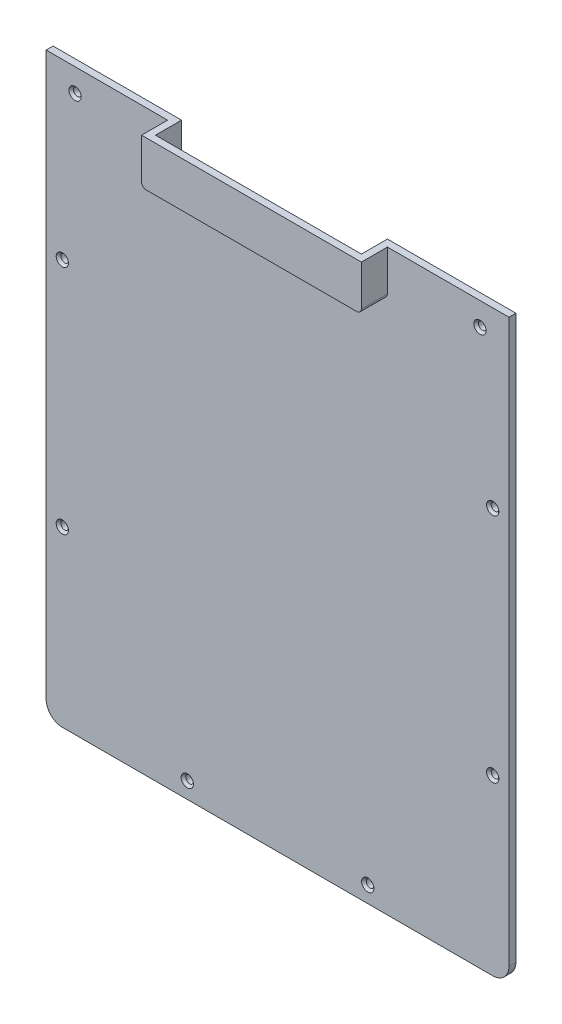
from build123d import *

# Parameters (mm, degrees)
SKETCH1_W           = 200
SKETCH1_H           = 250
BOSS_EXTRUDE1_DEPTH = 3
FILLET1_R           = 7
SKETCH2_W           = 89
SKETCH2_H           = 16.5
CUT_EXTRUDE2_DEPTH  = 3
EXTRUDE_THIN1_DEPTH = 8.25
SKETCH4_W           = 95
SKETCH4_H           = 19.5
BOSS_EXTRUDE2_DEPTH = 3
FILLET2_R           = 2
FILLET3_R           = 2
SKETCH5_R           = 1.65
CUT_EXTRUDE3_DEPTH  = 4
CHAMFER1_SIZE       = 1


with BuildPart() as part:
    # Sketch1 → Boss-Extrude1 (new body)
    with BuildSketch(Plane.XY):
        with Locations((100, 125)):
            Rectangle(SKETCH1_W, SKETCH1_H)
    extrude(amount=BOSS_EXTRUDE1_DEPTH)

    # Fillet1
    fillet1_edges = [part.edges().sort_by_distance(p)[0] for p in [
        (200, 0, 1.5),
        (0, 0, 1.5),
    ]]
    fillet(fillet1_edges, radius=FILLET1_R)

    # Sketch2 → Cut-Extrude2 (cut)
    with BuildSketch(Plane.XY):
        with Locations((100, 241.75)):
            Rectangle(SKETCH2_W, SKETCH2_H)
    extrude(amount=CUT_EXTRUDE2_DEPTH, mode=Mode.SUBTRACT)

    # Sketch3 → Extrude-Thin1 (add)
    with BuildSketch(Plane.XY.offset(3)):
        Polygon((144.5, 250), (144.5, 233.5), (55.5, 233.5), (55.5, 250), (52.5, 250), (52.5, 230.5), (147.5, 230.5), (147.5, 250), align=None)
    extrude(amount=EXTRUDE_THIN1_DEPTH)

    # Sketch4 → Boss-Extrude2 (add)
    with BuildSketch(Plane.XY.offset(11.25)):
        with Locations((100, 240.25)):
            Rectangle(SKETCH4_W, SKETCH4_H)
    extrude(amount=BOSS_EXTRUDE2_DEPTH)

    # Fillet2
    fillet2_edges = [part.edges().sort_by_distance(p)[0] for p in [
        (144.5, 233.5, 5.625),
        (55.5, 233.5, 5.625),
    ]]
    fillet(fillet2_edges, radius=FILLET2_R)

    # Fillet3
    fillet3_edges = [part.edges().sort_by_distance(p)[0] for p in [
        (52.5, 230.5, 8.625),
        (147.5, 230.5, 8.625),
    ]]
    fillet(fillet3_edges, radius=FILLET3_R)

    # Sketch5 → Cut-Extrude3 (cut, through all)
    with BuildSketch(Plane.XY.offset(3)):
        with Locations((12.5, 240)):
            Circle(SKETCH5_R)
        with Locations((187.5, 240)):
            Circle(SKETCH5_R)
        with Locations((7, 175)):
            Circle(SKETCH5_R)
        with Locations((7, 75)):
            Circle(SKETCH5_R)
        with Locations((61, 7)):
            Circle(SKETCH5_R)
        with Locations((139, 7)):
            Circle(SKETCH5_R)
        with Locations((193, 175)):
            Circle(SKETCH5_R)
        with Locations((193, 75)):
            Circle(SKETCH5_R)
    extrude(amount=-CUT_EXTRUDE3_DEPTH, mode=Mode.SUBTRACT)

    # Chamfer1
    chamfer1_edges = [part.edges().sort_by_distance(p)[0] for p in [
        (185.85, 240, 3),
        (5.35, 175, 3),
        (5.35, 75, 3),
        (59.35, 7, 3),
        (191.35, 75, 3),
        (191.35, 175, 3),
        (137.35, 7, 3),
        (10.85, 240, 3),
    ]]
    chamfer(chamfer1_edges, length=CHAMFER1_SIZE)


solid = part.part
